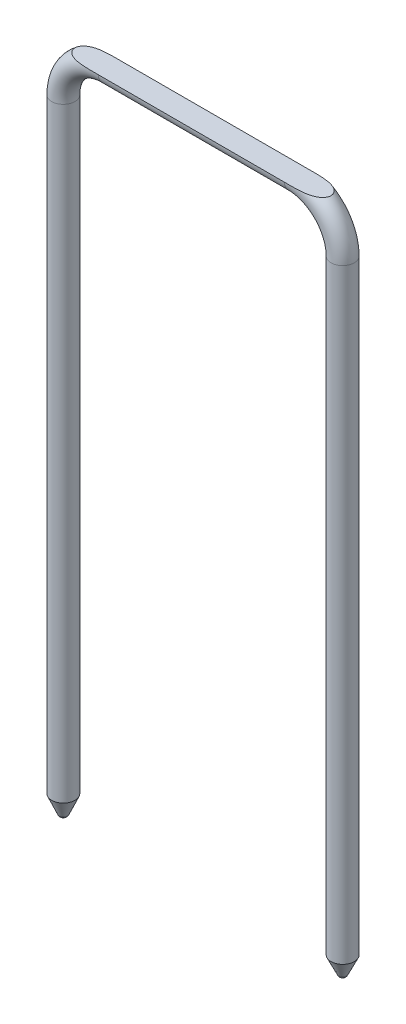
from build123d import *

# Parameters (mm, degrees)
SKETCH3_R          = 2.5
SKETCH7_W          = 6.517782954
SKETCH7_H          = 4.322109435
CUT_EXTRUDE1_DEPTH = 72


with BuildPart() as part:
    # Sweep1: sweep along a path in Sketch4
    with BuildLine(Plane.XY) as sweep1_path:
        Line((0, 0), (0, 130))
        ThreePointArc((0, 130), (2.928932188, 137.071067812), (10, 140))
        Line((10, 140), (50, 140))
        ThreePointArc((50, 140), (57.071067812, 137.071067812), (60, 130))
        Line((60, 130), (60, 24.600902506))
        Line((60, 24.600902506), (60, 0))
    # Sketch3 → Sweep1 (sweep)
    with BuildSketch(Plane(origin=(0, 0, 0), x_dir=(1, 0, 0), z_dir=(0, 1, 0))):
        Circle(SKETCH3_R)
    sweep(path=sweep1_path.line)

    # Sketch5 → Revolve1 (revolve)
    with BuildSketch(Plane.XY):
        with BuildLine():
            Line((0, 0), (0, -4.2))
            add(Edge.make_bspline(
                [(0.921927602, -3.641780971), (0.629243953, -4.327906562), (0, -4.2)],
                knots=[0, 0, 0, 1, 1, 1], degree=2))
            Line((0.921927602, -3.641780971), (2.5, 0))
            Line((2.5, 0), (0, 0))
        make_face()
    revolve(axis=Axis((0, 0, 0), (0, -1, 0)))

    # Sketch6 → Revolve2 (revolve)
    with BuildSketch(Plane.XY):
        with BuildLine():
            Line((57.5, 0), (60, 0))
            Line((60, 0), (60, -4))
            add(Edge.make_bspline(
                [(59.123790654, -3.437958358), (59.375682143, -4.137387225), (60, -4)],
                knots=[0, 0, 0, 1, 1, 1], degree=2))
            Line((59.123790654, -3.437958358), (57.5, 0))
        make_face()
    revolve(axis=Axis((60, 0, 0), (0, -1, 0)))

    # Sketch7 → Cut-Extrude1 (cut)
    with BuildSketch(Plane(origin=(0, 0, 0), x_dir=(0, 0, -1), z_dir=(1, 0, 0))):
        with Locations((-0.143512102, 142.161054718)):
            Rectangle(SKETCH7_W, SKETCH7_H)
    extrude(amount=CUT_EXTRUDE1_DEPTH, mode=Mode.SUBTRACT)


solid = part.part
